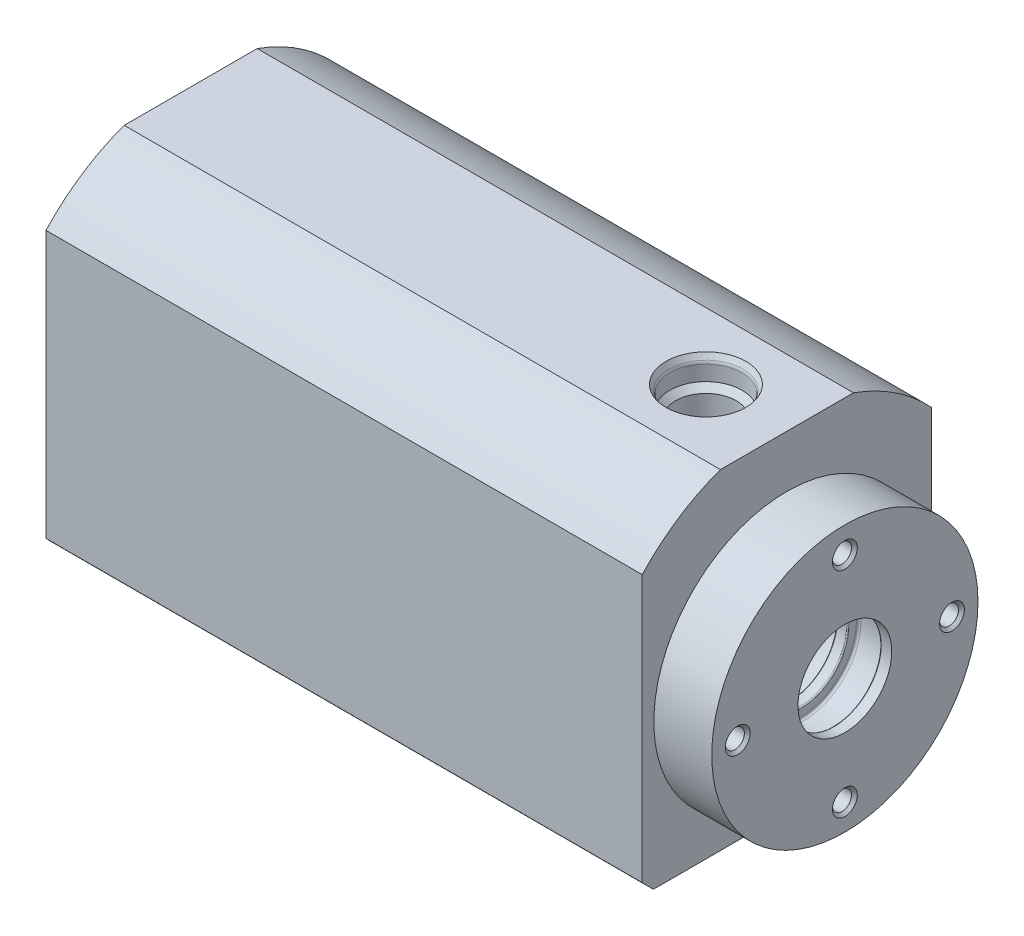
from build123d import *

# Parameters (mm, degrees)
SKETCH_2_OUTSIDE_W          = 99.676
SKETCH_2_OUTSIDE_H          = 99.676
CUT_EXTRUDE_1_DEPTH         = 114
CHAMFER_1_SIZE              = 1.3
CHAMFER_1_SIZE2             = 4.85166605
FILLET_1_R                  = 2
FILLET_2_R                  = 1
PATTERN_CIRCULAR_1_COUNT    = 4
HOLE_WIZARD_M63_D           = 4.95
HOLE_WIZARD_M63_DEPTH       = 19
HOLE_WIZARD_M63_CSINK_D     = 6.95
HOLE_WIZARD_M63_CSINK_ANGLE = 90
HOLE_WIZARD_M63_TIP         = 1.487130032
PATTERN_CIRCULAR_2_COUNT    = 4
CHAMFER_2_SIZE              = 1
FILLET_3_R                  = 0.4
FILLET_4_R                  = 0.2


with BuildPart() as part:
    # Эскиз1 → Повернуть1 (revolve)
    with BuildSketch(Plane.XY):
        Polygon((0, 34), (0, 16), (85, 16), (85, 8.1), (99.9, 8.1), (99.9, 9.9), (103.4, 9.9), (103.4, 8.1), (105.4, 8.1), (105.4, 10), (111, 10), (111, 8.1), (113, 8.1), (113, 23), (103, 23), (103, 34), align=None)
    revolve(axis=Axis((0, 0, 0), (-1, 0, 0)))

    # Эскиз2 outside → Вырез-Вытянуть1 (cut, through all)
    with BuildSketch(Plane.ZY):
        Rectangle(SKETCH_2_OUTSIDE_W, SKETCH_2_OUTSIDE_H)
        with BuildLine():
            Line((-11.489125293, 32), (11.489125293, 32))
            ThreePointArc((11.489125293, 32), (18.786140377, 28.338682569), (25, 23.043437244))
            Line((25, 23.043437244), (25, -25))
            Line((25, -25), (-25, -25))
            Line((-25, -25), (-25, 23.043437244))
            ThreePointArc((-25, 23.043437244), (-18.786140377, 28.338682569), (-11.489125293, 32))
        make_face(mode=Mode.SUBTRACT)
    extrude(amount=-CUT_EXTRUDE_1_DEPTH, mode=Mode.SUBTRACT)

    # Фаска1
    chamfer_1_edges = [part.edges().sort_by_distance(p)[0] for p in [
        (0, -16, 0),
    ]]
    chamfer_1_side = [part.faces().sort_by_distance(p)[0] for p in [
        (0, 31.241778397, 0),
    ]]
    chamfer(chamfer_1_edges, length=CHAMFER_1_SIZE, length2=CHAMFER_1_SIZE2, reference=chamfer_1_side[0])

    # Скругление1
    fillet_1_edges = [part.edges().sort_by_distance(p)[0] for p in [
        (4.85166605, -16, 0),
    ]]
    fillet(fillet_1_edges, radius=FILLET_1_R)

    # Скругление2
    fillet_2_edges = [part.edges().sort_by_distance(p)[0] for p in [
        (0, -17.3, 0),
    ]]
    fillet(fillet_2_edges, radius=FILLET_2_R)

    # Эскиз5 → Отверстие обработанное метчиком M64 (revolve, cut)
    with BuildSketch(Plane(origin=(0, 16.970562748, 16.970562748), x_dir=(0, 0, 1), z_dir=(0, 1, 0))):
        Polygon((0, 0), (0, 17.287130032), (2.475, 15.8), (2.475, 1), (3.475, 0), align=None)
    hole_wizard_m64 = revolve(axis=Axis((-6.35, 16.970562748, 16.970562748), (1, 0, 0)), mode=Mode.SUBTRACT)

    # Круговой массив1: Отверстие обработанное метчиком M64 ×4 about axis
    pattern_circular_1_axis = Axis((0, 0, 0), (1, 0, 0))
    for i in range(1, PATTERN_CIRCULAR_1_COUNT):
        add(hole_wizard_m64.rotate(pattern_circular_1_axis, i * 360 / PATTERN_CIRCULAR_1_COUNT), mode=Mode.SUBTRACT)

    # Отверстие обработанное метчиком M63
    with Locations(Plane(origin=(0, -25, 0), x_dir=(-1, 0, 0), z_dir=(0, -1, 0))):
        with Locations((-95, -19), (-95, 19), (-43, 19), (-43, -19)):
            CounterSinkHole(HOLE_WIZARD_M63_D / 2, HOLE_WIZARD_M63_CSINK_D / 2, depth=HOLE_WIZARD_M63_DEPTH, counter_sink_angle=HOLE_WIZARD_M63_CSINK_ANGLE)
            with Locations((0, 0, -(HOLE_WIZARD_M63_DEPTH + HOLE_WIZARD_M63_TIP / 2))):  # 118° drill point
                Cone(0, HOLE_WIZARD_M63_D / 2, HOLE_WIZARD_M63_TIP, mode=Mode.SUBTRACT)

    # Sketch2 → Cut-Revolve1 (revolve, cut)
    with BuildSketch(Plane(origin=(89, 32, 0), x_dir=(1, 0, 0), z_dir=(0, 0, 1))):
        with BuildLine():
            Line((0, 0), (0, -22.103445097))
            Line((0, -22.103445097), (-5.165, -19))
            Line((-5.165, -19), (-5.165, -13))
            Line((-5.165, -13), (-5.215, -13))
            Line((-5.215, -13), (-5.215, -5.035))
            Line((-5.215, -5.035), (-6.25, -4))
            Line((-6.25, -4), (-6.25, -1.393782217))
            ThreePointArc((-6.25, -1.393782217), (-6.284074174, -1.134963172), (-6.383974596, -0.893782217))
            Line((-6.383974596, -0.893782217), (-6.9, 0))
            Line((-6.9, 0), (0, 0))
        make_face()
    revolve(axis=Axis((89, 32, 0), (0, 1, 0)), mode=Mode.SUBTRACT)

    # Эскиз12 → Отверстие обработанное метчиком M42 (revolve, cut)
    with BuildSketch(Plane(origin=(113, 18.5, 0), x_dir=(0, 0, -1), z_dir=(0, 1, 0))):
        Polygon((0, 0), (0, 12.491420021), (1.65, 11.5), (1.65, 0.5), (2.15, 0), align=None)
    hole_wizard_m42 = revolve(axis=Axis((119.35, 18.5, 0), (-1, 0, 0)), mode=Mode.SUBTRACT)

    # Круговой массив2: Отверстие обработанное метчиком M42 ×4 about axis
    pattern_circular_2_axis = Axis((0, 0, 0), (1, 0, 0))
    for i in range(1, PATTERN_CIRCULAR_2_COUNT):
        add(hole_wizard_m42.rotate(pattern_circular_2_axis, i * 360 / PATTERN_CIRCULAR_2_COUNT), mode=Mode.SUBTRACT)

    # Фаска2
    chamfer_2_edges = [part.edges().sort_by_distance(p)[0] for p in [
        (85, -8.1, 0),
    ]]
    chamfer(chamfer_2_edges, length=CHAMFER_2_SIZE)

    # Скругление3
    fillet_3_edges = [part.edges().sort_by_distance(p)[0] for p in [
        (111, -10, 0),
        (105.4, -10, 0),
        (103.4, -9.9, 0),
        (99.9, -9.9, 0),
    ]]
    fillet(fillet_3_edges, radius=FILLET_3_R)

    # Скругление4
    fillet_4_edges = [part.edges().sort_by_distance(p)[0] for p in [
        (111, -8.1, 0),
        (105.4, -8.1, 0),
        (103.4, -8.1, 0),
        (99.9, -8.1, 0),
    ]]
    fillet(fillet_4_edges, radius=FILLET_4_R)


solid = part.part
